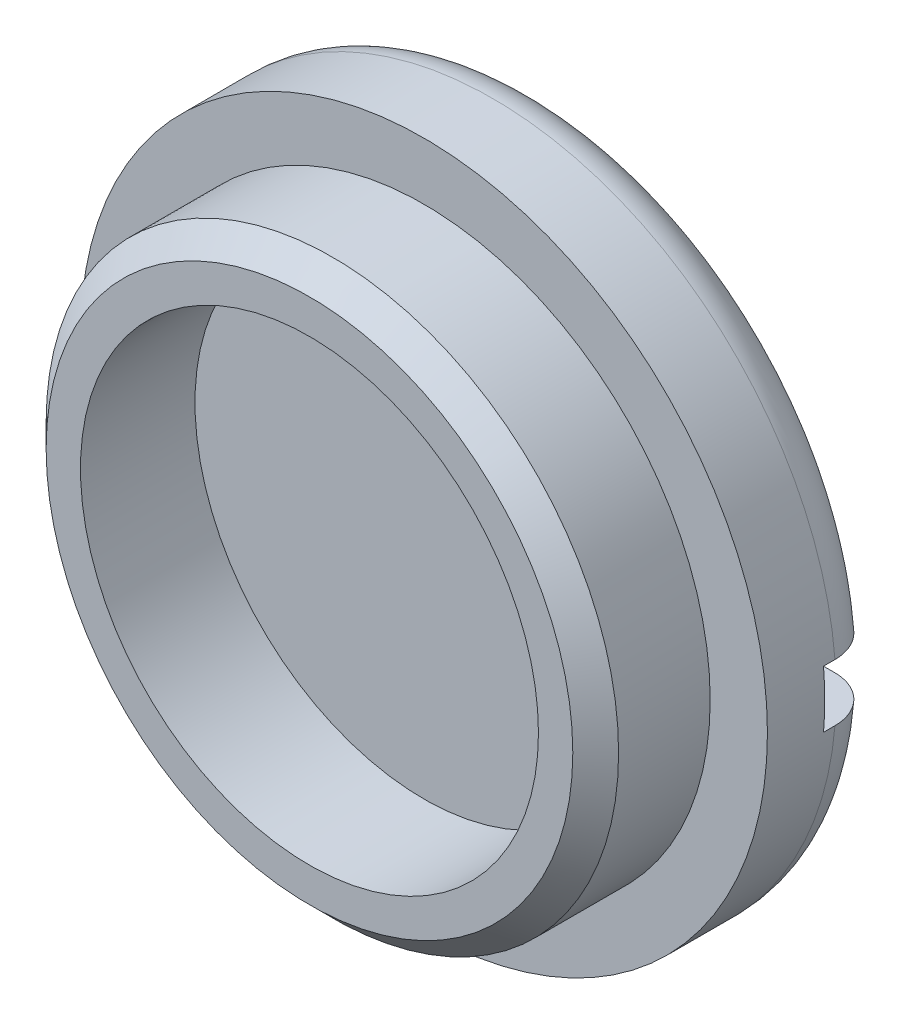
from build123d import *

# Parameters (mm, degrees)
CUT_EXTRUDE1_DEPTH      = 20.05
CUT_EXTRUDE1_DEPTH_BACK = 20.05
FILLET1_R               = 2.54
CHAMFER1_SIZE           = 1.27


with BuildPart() as part:
    # Sketch1 → Revolve1 (revolve)
    with BuildSketch(Plane(origin=(0, 0, 0), x_dir=(1, 0, 0), z_dir=(0, 1, 0))):
        Polygon((12.7, 0), (15.875, 0), (15.875, 6.35), (19.05, 6.35), (19.05, 12.7), (0, 12.7), (0, 6.35), (12.7, 6.35), align=None)
    revolve(axis=Axis((0, 0, 31.989022308), (0, 0, -1)))

    # Sketch2 → Cut-Extrude1 (cut, two sides)
    with BuildSketch(Plane(origin=(0, 0, 0), x_dir=(0, 0, -1), z_dir=(1, 0, 0))) as cut_extrude1_sk:
        Polygon((71.164271634, -1.5875), (12.7, -1.5875), (9.525, -1.5875), (9.525, 1.5875), (12.7, 1.5875), (71.164271634, 1.5875), (188.092814902, 1.5875), (188.092814902, -1.5875), align=None)
    extrude(amount=CUT_EXTRUDE1_DEPTH, mode=Mode.SUBTRACT)
    extrude(cut_extrude1_sk.sketch, amount=-CUT_EXTRUDE1_DEPTH_BACK, mode=Mode.SUBTRACT)

    # Fillet1
    fillet1_edges = [part.edges().sort_by_distance(p)[0] for p in [
        (0, -19.05, -12.7),
        (0, 19.05, -12.7),
    ]]
    fillet(fillet1_edges, radius=FILLET1_R)

    # Chamfer1
    chamfer1_edges = [part.edges().sort_by_distance(p)[0] for p in [
        (-15.875, 0, 0),
    ]]
    chamfer(chamfer1_edges, length=CHAMFER1_SIZE)


solid = part.part
